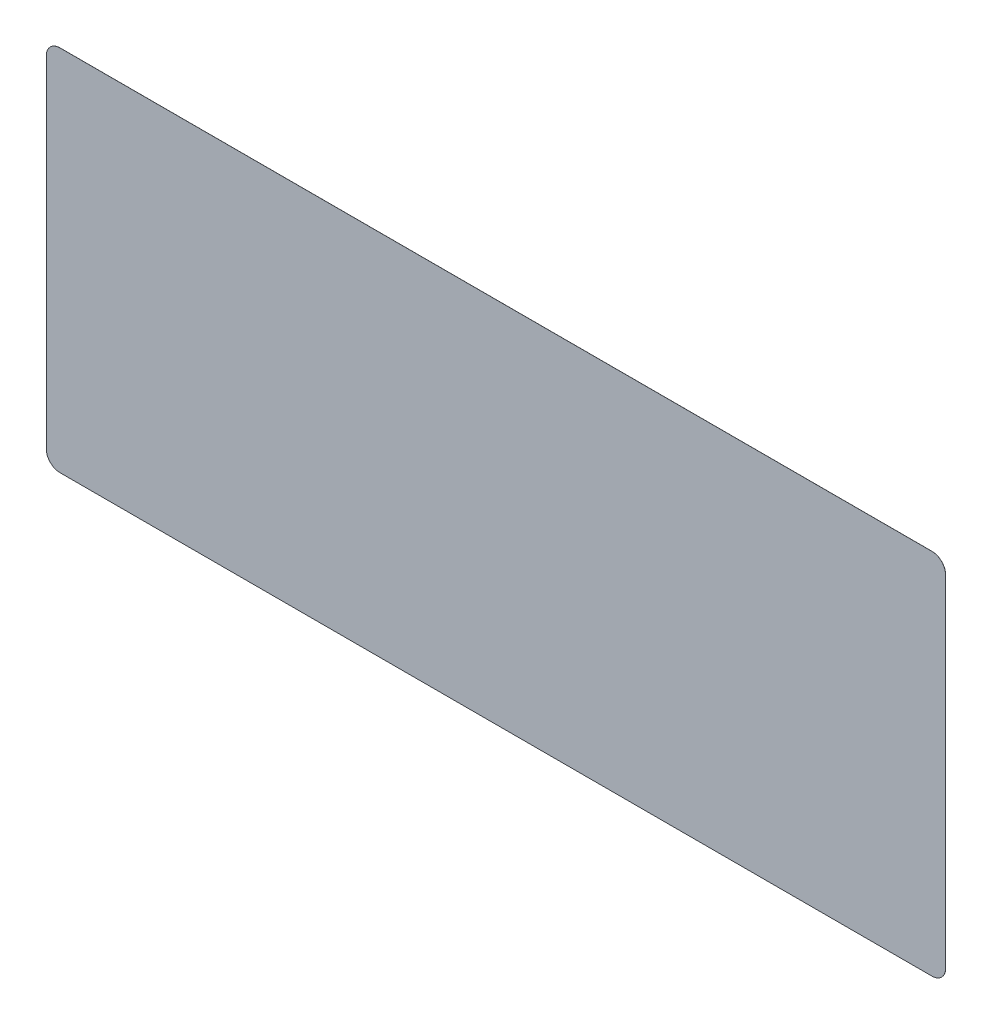
from build123d import *

# Parameters (mm, degrees)
BOSS_EXTRUDE1_DEPTH = 0.01


with BuildPart() as part:
    # Sketch1 → Boss-Extrude1 (new body)
    with BuildSketch(Plane.XY):
        with BuildLine():
            Line((78, 137), (206, 137))
            ThreePointArc((206, 137), (207.414213562, 136.414213562), (208, 135))
            Line((208, 135), (208, 85))
            ThreePointArc((208, 85), (207.414213562, 83.585786438), (206, 83))
            Line((206, 83), (78, 83))
            ThreePointArc((78, 83), (76.585786438, 83.585786438), (76, 85))
            Line((76, 85), (76, 135))
            ThreePointArc((76, 135), (76.585786438, 136.414213562), (78, 137))
        make_face()
    extrude(amount=BOSS_EXTRUDE1_DEPTH)


solid = part.part
